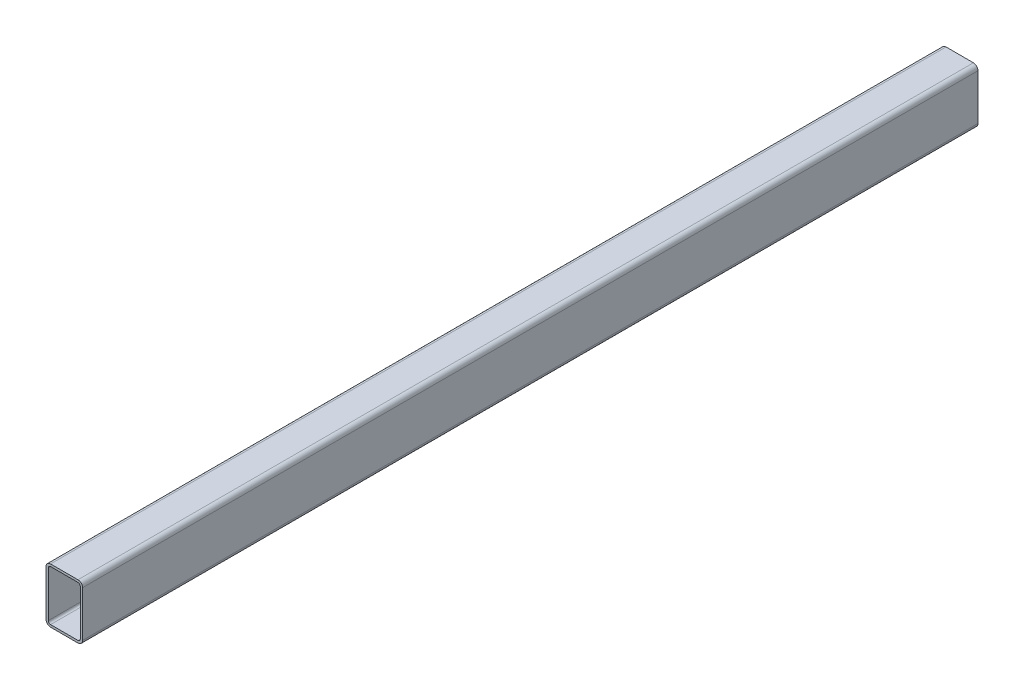
from build123d import *

# Parameters (mm, degrees)
BOSS_EXTRUDE2_DEPTH = 622.3


with BuildPart() as part:
    # Sketch13 → Boss-Extrude2 (new body, symmetric)
    with BuildSketch(Plane.XY):
        with BuildLine():
            Line((19.05, -38.1), (-19.05, -38.1))
            ThreePointArc((-19.05, -38.1), (-23.540128061, -36.240128061), (-25.4, -31.75))
            Line((-25.4, -31.75), (-25.4, 31.75))
            ThreePointArc((-25.4, 31.75), (-23.540128061, 36.240128061), (-19.05, 38.1))
            Line((-19.05, 38.1), (19.05, 38.1))
            ThreePointArc((19.05, 38.1), (23.540128061, 36.240128061), (25.4, 31.75))
            Line((25.4, 31.75), (25.4, -31.75))
            ThreePointArc((25.4, -31.75), (23.540128061, -36.240128061), (19.05, -38.1))
        make_face()
        with BuildLine():
            Line((19.05, -34.925), (-19.05, -34.925))
            ThreePointArc((-19.05, -34.925), (-21.29506403, -33.99506403), (-22.225, -31.75))
            Line((-22.225, -31.75), (-22.225, 31.75))
            ThreePointArc((-22.225, 31.75), (-21.29506403, 33.99506403), (-19.05, 34.925))
            Line((-19.05, 34.925), (19.05, 34.925))
            ThreePointArc((19.05, 34.925), (21.29506403, 33.99506403), (22.225, 31.75))
            Line((22.225, 31.75), (22.225, -31.75))
            ThreePointArc((22.225, -31.75), (21.29506403, -33.99506403), (19.05, -34.925))
        make_face(mode=Mode.SUBTRACT)
    extrude(amount=BOSS_EXTRUDE2_DEPTH, both=True)


solid = part.part
